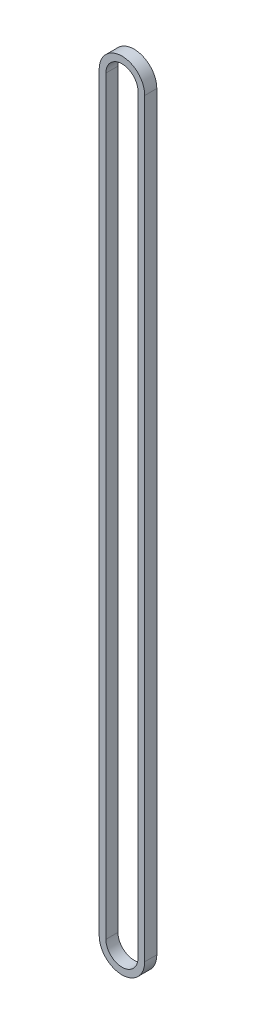
from build123d import *

# Parameters (mm, degrees)
EXTRUDE_1_DEPTH = 4.5


with BuildPart() as part:
    # Эскиз1 → Бобышка-Вытянуть1 (new body)
    with BuildSketch(Plane.XY):
        with BuildLine():
            Line((-8.5, -140), (-8.5, 140))
            ThreePointArc((-8.5, 140), (0, 148.5), (8.5, 140))
            Line((8.5, 140), (8.5, -140))
            ThreePointArc((8.5, -140), (0, -148.5), (-8.5, -140))
        make_face()
        with BuildLine():
            Line((-6, -140), (-6, 140))
            ThreePointArc((-6, 140), (0, 146), (6, 140))
            Line((6, 140), (6, -140))
            ThreePointArc((6, -140), (0, -146), (-6, -140))
        make_face(mode=Mode.SUBTRACT)
    extrude(amount=EXTRUDE_1_DEPTH)


solid = part.part
